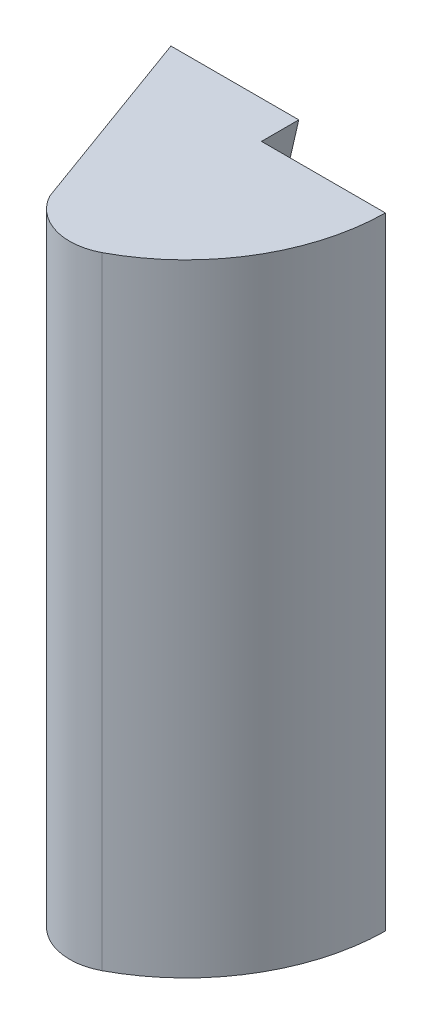
from build123d import *

# Parameters (mm, degrees)
BOSS_EXTRUDE1_DEPTH = 50
CUT_EXTRUDE1_START  = -50
CUT_EXTRUDE1_DEPTH  = 50
SKETCH3_R           = 1.6
CUT_EXTRUDE2_DEPTH  = 15
SKETCH6_R           = 1.6
CUT_EXTRUDE4_DEPTH  = 3
SKETCH7_W           = 1.666520658
SKETCH7_H           = 50
CUT_EXTRUDE5_DEPTH  = 3
CUT_EXTRUDE6_DEPTH  = 3


with BuildPart() as part:
    # Sketch1 → Boss-Extrude1 (new body)
    with BuildSketch(Plane(origin=(0, 0, 0), x_dir=(1, 0, 0), z_dir=(0, 1, 0))):
        with BuildLine():
            Line((13.159597133, 18.793852416), (-6.840402867, 18.793852416))
            Line((-6.840402867, 18.793852416), (0, 0))
            ThreePointArc((0, 0), (10.472132847, 6.671484404), (13.159597133, 18.793852416))
        make_face()
    extrude(amount=BOSS_EXTRUDE1_DEPTH)

    # Sketch5 → Cut-Extrude1 (cut)
    with BuildSketch(Plane(origin=(0, 50, 0), x_dir=(1, 0, 0), z_dir=(0, 1, 0)).offset(CUT_EXTRUDE1_START)):
        with BuildLine():
            ThreePointArc((4.765485224, 1.634621553), (1.372703273, 1.322660653), (-1.265925556, 3.478101879))
            Line((-1.265925556, 3.478101879), (0, 0))
            ThreePointArc((0, 0), (2.446582795, 0.63119464), (4.765485224, 1.634621553))
        make_face()
    extrude(amount=CUT_EXTRUDE1_DEPTH, mode=Mode.SUBTRACT)

    # Sketch3 → Cut-Extrude2 (cut)
    with BuildSketch(Plane(origin=(0, 0, -18.793852416), x_dir=(-1, 0, 0), z_dir=(0, 0, -1))):
        with Locations((-3.159597133, 19)):
            Circle(SKETCH3_R)
        with Locations((-3.159597133, 31)):
            Circle(SKETCH3_R)
    extrude(amount=-CUT_EXTRUDE2_DEPTH, mode=Mode.SUBTRACT)

    # Sketch6 → Cut-Extrude4 (cut)
    with BuildSketch(Plane(origin=(0, 0, -18.793852416), x_dir=(-1, 0, 0), z_dir=(0, 0, -1))):
        Polygon((0.945619298, 36), (-0.208721658, 36), (-3.440876334, 50), (-13.159597133, 50), (-13.159597133, 0), (-3.440876334, 0), (-0.208721658, 14), (0.945619298, 14), align=None)
        with Locations((-3.159597133, 19)):
            Circle(SKETCH6_R, mode=Mode.SUBTRACT)
        with Locations((-3.159597133, 31)):
            Circle(SKETCH6_R, mode=Mode.SUBTRACT)
    extrude(amount=-CUT_EXTRUDE4_DEPTH, mode=Mode.SUBTRACT)

    # Sketch7 → Cut-Extrude5 (cut)
    with BuildSketch(Plane(origin=(0, 0, -18.793852416), x_dir=(-1, 0, 0), z_dir=(0, 0, -1))):
        with Locations((-13.992857462, 25)):
            Rectangle(SKETCH7_W, SKETCH7_H)
    extrude(amount=-CUT_EXTRUDE5_DEPTH, mode=Mode.SUBTRACT)

    # Sketch6_5 → Cut-Extrude6 (cut)
    with BuildSketch(Plane(origin=(0, 0, -18.793852416), x_dir=(-1, 0, 0), z_dir=(0, 0, -1))):
        Polygon((0.945619298, 36), (0.945619298, 31), (0.945619298, 19), (0.945619298, 14), (1.945619298, 14), (1.945619298, 36), align=None)
    extrude(amount=-CUT_EXTRUDE6_DEPTH, mode=Mode.SUBTRACT)


solid = part.part
